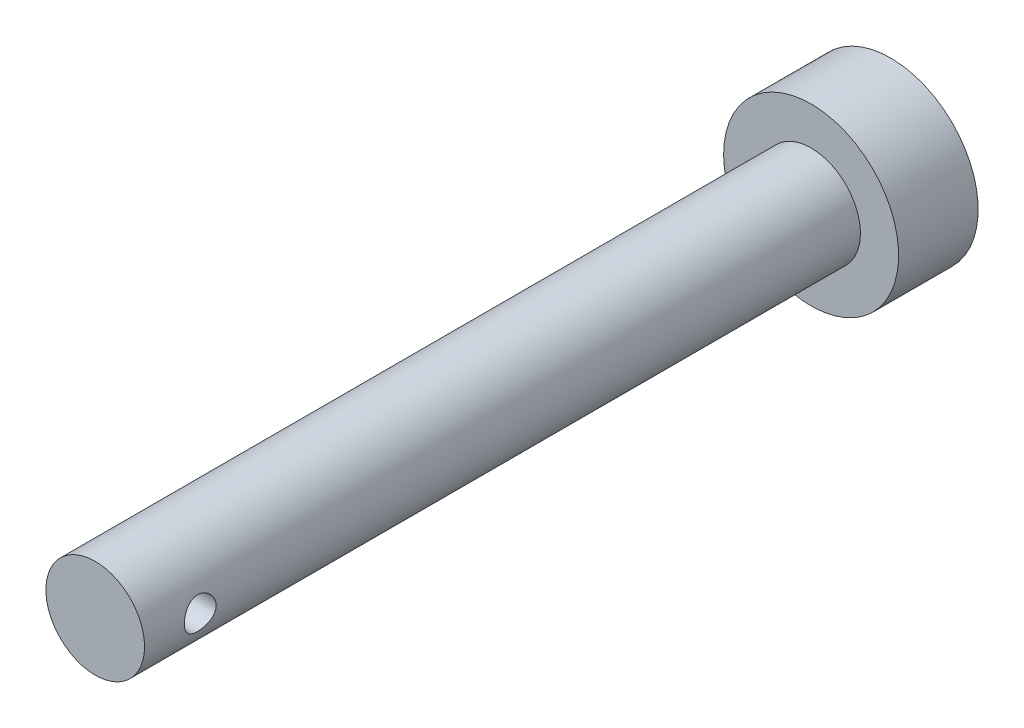
from build123d import *

# Parameters (mm, degrees)
SKETCH1_R               = 3.1
BOSS_EXTRUDE1_DEPTH     = 45
SKETCH2_R               = 1
CUT_EXTRUDE1_DEPTH      = 4.1
CUT_EXTRUDE1_DEPTH_BACK = 4.1
SKETCH3_R               = 5.5
BOSS_EXTRUDE2_DEPTH     = 5


with BuildPart() as part:
    # Sketch1 → Boss-Extrude1 (new body)
    with BuildSketch(Plane.XY):
        Circle(SKETCH1_R)
    extrude(amount=BOSS_EXTRUDE1_DEPTH)

    # Sketch2 → Cut-Extrude1 (cut, two sides)
    with BuildSketch(Plane(origin=(0, 0, 0), x_dir=(0, 0, -1), z_dir=(1, 0, 0))) as cut_extrude1_sk:
        with Locations((-41.5, 0)):
            Circle(SKETCH2_R)
    extrude(amount=CUT_EXTRUDE1_DEPTH, mode=Mode.SUBTRACT)
    extrude(cut_extrude1_sk.sketch, amount=-CUT_EXTRUDE1_DEPTH_BACK, mode=Mode.SUBTRACT)

    # Sketch3 → Boss-Extrude2 (add)
    with BuildSketch(Plane(origin=(0, 0, 0), x_dir=(-1, 0, 0), z_dir=(0, 0, -1))):
        Circle(SKETCH3_R)
    extrude(amount=BOSS_EXTRUDE2_DEPTH)


solid = part.part
